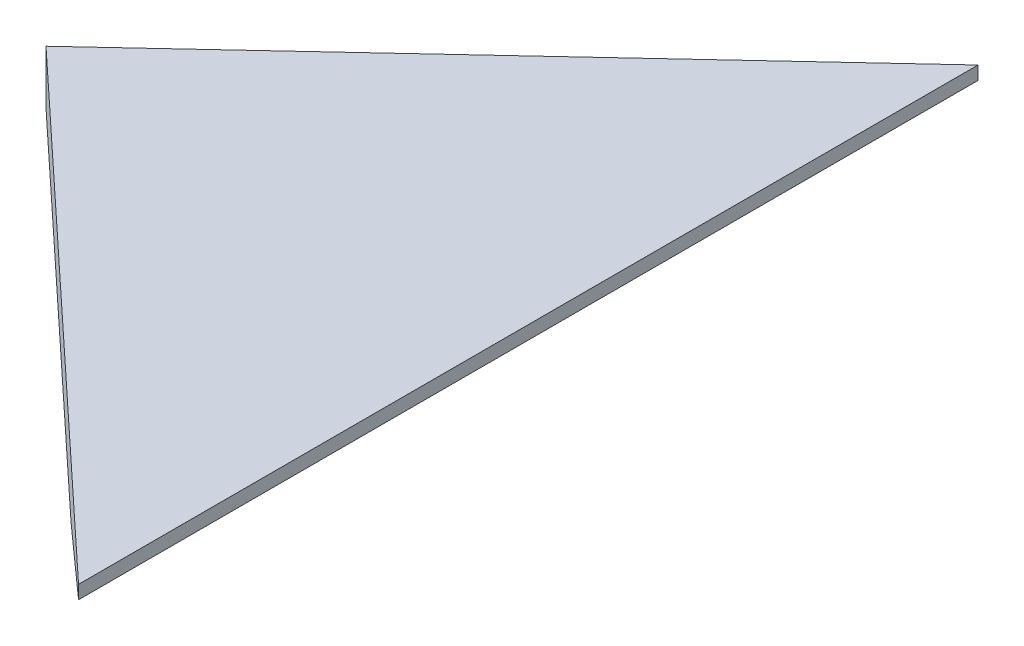
from build123d import *

# Parameters (mm, degrees)
BOSS_EXTRUDE1_DEPTH = 152.4
SKETCH2_OUTSIDE_W   = 181.454
SKETCH2_OUTSIDE_H   = 371.954
CUT_EXTRUDE2_DEPTH  = 13.7


with BuildPart() as part:
    # Sketch1 → Boss-Extrude1 (new body, symmetric)
    with BuildSketch(Plane.XY):
        Polygon((0, 0), (0, 12.7), (114.3, 12.7), (114.3, 9.525), (88.13027758, 0), align=None)
    extrude(amount=BOSS_EXTRUDE1_DEPTH, both=True)

    # Sketch2 outside → Cut-Extrude2 (cut, through all)
    with BuildSketch(Plane(origin=(0, 0, 0), x_dir=(1, 0, 0), z_dir=(0, 1, 0))):
        with Locations((57.15, 0)):
            Rectangle(SKETCH2_OUTSIDE_W, SKETCH2_OUTSIDE_H)
        Polygon((0, 0), (155.264337474, -144.786337034), (155.264337474, 144.786337034), align=None, mode=Mode.SUBTRACT)
    extrude(amount=CUT_EXTRUDE2_DEPTH, mode=Mode.SUBTRACT)


solid = part.part
